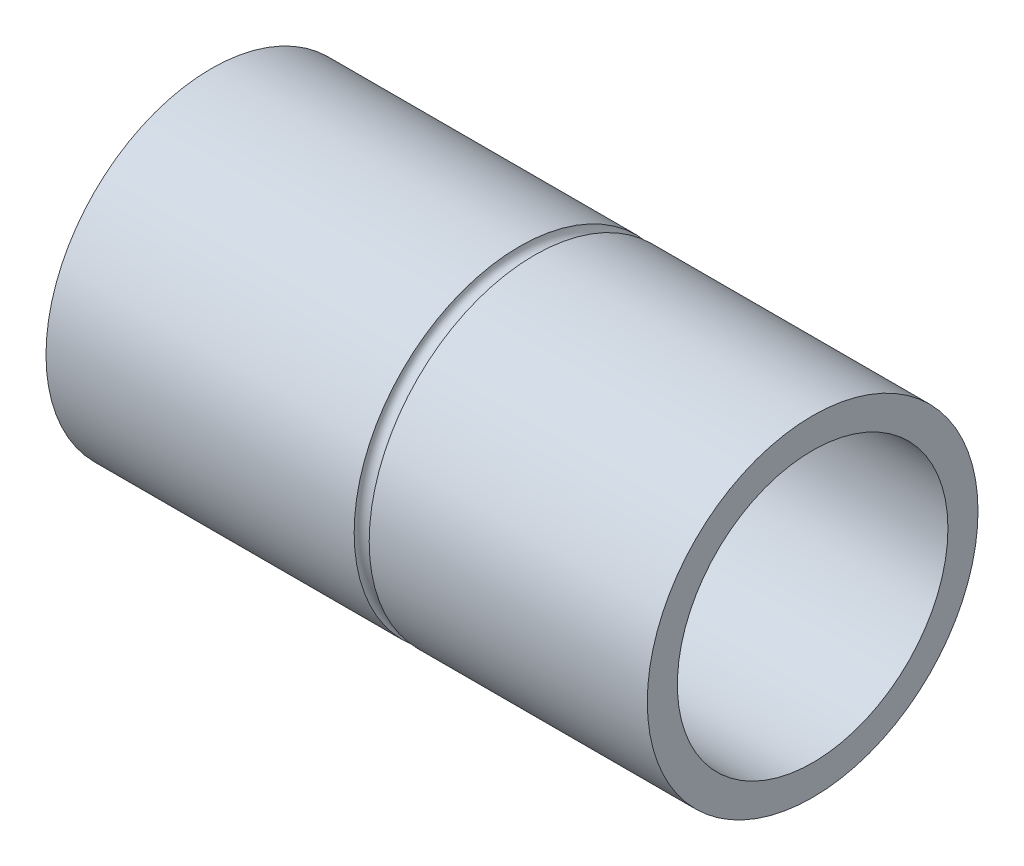
from build123d import *

# Parameters (mm, degrees)
SKETCH1_R               = 55
BOSS_EXTRUDE1_DEPTH     = 200
SKETCH2_R               = 45
CUT_EXTRUDE1_DEPTH      = 190
SKETCH3_R               = 17.5
CUT_EXTRUDE2_DEPTH      = 1
CUT_EXTRUDE2_DEPTH_BACK = 201
SKETCH4_R               = 5
CUT_EXTRUDE3_DEPTH      = 2
SKETCH5_R               = 22.5
CUT_EXTRUDE4_DEPTH      = 2
CUT_SWEEP1_PROFILE_R    = 2.5
SKETCH58_R              = 2.5
CUT_EXTRUDE5_DEPTH      = 2


with BuildPart() as part:
    # Sketch1 → Boss-Extrude1 (new body)
    with BuildSketch(Plane(origin=(0, 0, 0), x_dir=(0, 0, -1), z_dir=(1, 0, 0))):
        Circle(SKETCH1_R)
    extrude(amount=BOSS_EXTRUDE1_DEPTH)

    # Sketch2 → Cut-Extrude1 (cut)
    with BuildSketch(Plane(origin=(200, 0, 0), x_dir=(0, 0, -1), z_dir=(1, 0, 0))):
        Circle(SKETCH2_R)
    extrude(amount=-CUT_EXTRUDE1_DEPTH, mode=Mode.SUBTRACT)

    # Sketch3 → Cut-Extrude2 (cut, two sides)
    with BuildSketch(Plane.ZY) as cut_extrude2_sk:
        Circle(SKETCH3_R)
    extrude(amount=CUT_EXTRUDE2_DEPTH, mode=Mode.SUBTRACT)
    extrude(cut_extrude2_sk.sketch, amount=-CUT_EXTRUDE2_DEPTH_BACK, mode=Mode.SUBTRACT)

    # Sketch4 → Cut-Extrude3 (cut)
    with BuildSketch(Plane.ZY):
        with Locations((0, 34)):
            Circle(SKETCH4_R)
        with Locations((0, -34)):
            Circle(SKETCH4_R)
    extrude(amount=-CUT_EXTRUDE3_DEPTH, mode=Mode.SUBTRACT)

    # Sketch5 → Cut-Extrude4 (cut)
    with BuildSketch(Plane.ZY):
        Circle(SKETCH5_R)
    extrude(amount=-CUT_EXTRUDE4_DEPTH, mode=Mode.SUBTRACT)

    # Cut-Sweep1: sweep along a path in Sketch57
    with BuildLine(Plane(origin=(105, 0, 0), x_dir=(0, 0, -1), z_dir=(1, 0, 0))) as cut_sweep1_path:
        CenterArc((0, 0), 55, 0, 360)
    # Cut-Sweep1 profile (on start of the path) → Cut-Sweep1 (sweep, cut)
    with BuildSketch(Plane(origin=(105, 0, -55), x_dir=(0, 0, 1), z_dir=(0, 1, 0))):
        Circle(CUT_SWEEP1_PROFILE_R)
    sweep(path=cut_sweep1_path.line, mode=Mode.SUBTRACT)

    # Sketch58 → Cut-Extrude5 (cut)
    with BuildSketch(Plane.ZY.offset(-2)):
        with Locations((0, 34)):
            Circle(SKETCH58_R)
        with Locations((0, -34)):
            Circle(SKETCH58_R)
    extrude(amount=-CUT_EXTRUDE5_DEPTH, mode=Mode.SUBTRACT)


solid = part.part
